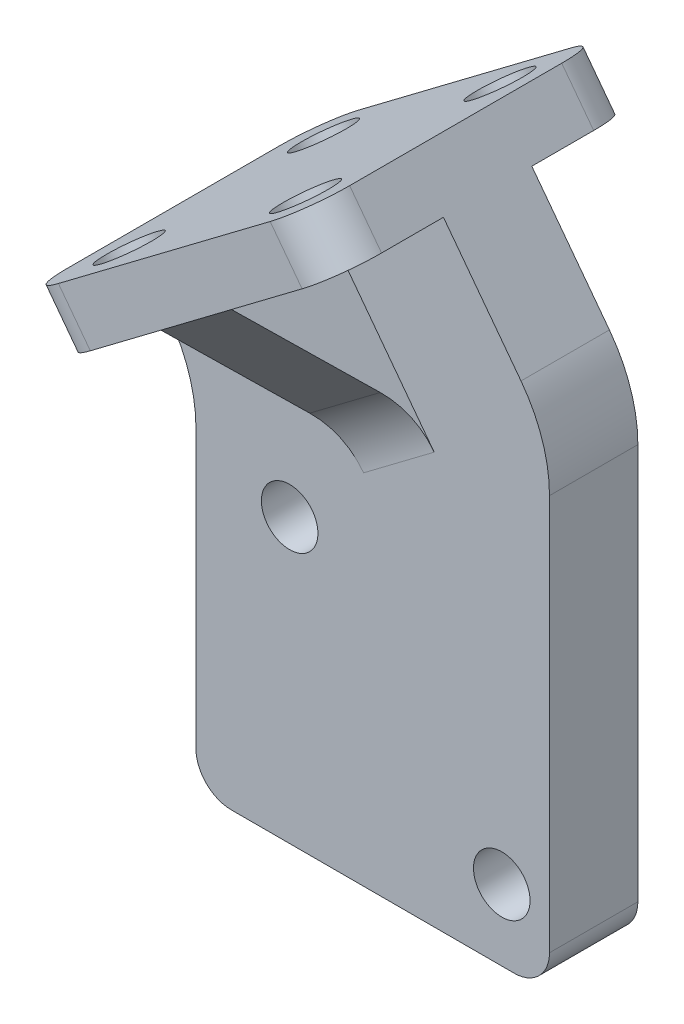
from build123d import *

# Parameters (mm, degrees)
SKETCH_1_R      = 1.6
EXTRUDE_1_DEPTH = 5
SKETCH_2_R      = 1.6
EXTRUDE_2_DEPTH = 3
EXTRUDE_START   = -7.5
EXTRUDE_4_DEPTH = 5
FILLET_1_R      = 5


with BuildPart() as part:
    # 草图1 → 凸台-拉伸1 (new body)
    with BuildSketch(Plane.XY):
        with BuildLine():
            Line((0, 2), (0, 17.705362587))
            ThreePointArc((0, 17.705362587), (-0.413410758, 20.243799839), (-1.61091592, 22.519882772))
            Line((-1.61091592, 22.519882772), (-1.972710201, 23))
            Line((-1.972710201, 23), (14, 35.036300463))
            Line((14, 35.036300463), (18.38908408, 29.211789163))
            ThreePointArc((18.38908408, 29.211789163), (19.586589242, 26.935706229), (20, 24.397268977))
            Line((20, 24.397268977), (20, 2))
            ThreePointArc((20, 2), (19.414213562, 0.585786438), (18, 0))
            Line((18, 0), (2, 0))
            ThreePointArc((2, 0), (0.585786438, 0.585786438), (0, 2))
        make_face()
        with Locations((5.3, 16)):
            Circle(SKETCH_1_R, mode=Mode.SUBTRACT)
        with Locations((17.3, 4)):
            Circle(SKETCH_1_R, mode=Mode.SUBTRACT)
    extrude(amount=EXTRUDE_1_DEPTH)

    # 草图2 → 凸台-拉伸2 (add)
    with BuildSketch(Plane(origin=(-11.768988292, 15.617974969, 0), x_dir=(0.79863551, 0.601815023, 0), z_dir=(-0.601815023, 0.79863551, 0))):
        with BuildLine():
            Line((29.766269115, -11), (14.766269115, -11))
            ThreePointArc((14.766269115, -11), (12.998502162, -10.267766953), (12.266269115, -8.5))
            Line((12.266269115, -8.5), (12.266269115, 3.5))
            ThreePointArc((12.266269115, 3.5), (12.998502162, 5.267766953), (14.766269115, 6))
            Line((14.766269115, 6), (29.766269115, 6))
            ThreePointArc((29.766269115, 6), (31.534036068, 5.267766953), (32.266269115, 3.5))
            Line((32.266269115, 3.5), (32.266269115, -8.5))
            ThreePointArc((32.266269115, -8.5), (31.534036068, -10.267766953), (29.766269115, -11))
        make_face()
        with Locations((16.016269115, 3)):
            Circle(SKETCH_2_R, mode=Mode.SUBTRACT)
        with Locations((28.516269115, 3)):
            Circle(SKETCH_2_R, mode=Mode.SUBTRACT)
        with Locations((28.516269115, -8)):
            Circle(SKETCH_2_R, mode=Mode.SUBTRACT)
        with Locations((16.016269115, -8)):
            Circle(SKETCH_2_R, mode=Mode.SUBTRACT)
    extrude(amount=EXTRUDE_2_DEPTH)

    # 草图6 → 凸台-拉伸4 (add)
    with BuildSketch(Plane(origin=(25.768988292, 19.418325494, 0), x_dir=(0, 0, -1), z_dir=(0.79863551, 0.601815023, 0)).offset(EXTRUDE_START)):
        Polygon((-11, 19.555823366), (-5, 12.262745076), (-5, 19.555823366), align=None)
        Polygon((0, 12.262745076), (6, 19.555823366), (0, 19.555823366), align=None)
    extrude(amount=-EXTRUDE_4_DEPTH)

    # 圆角1
    fillet_1_edges = [part.edges().sort_by_distance(p)[0] for p in [
        (10.40272898, 23.193638931, 5),
        (10.40272898, 23.193638931, 0),
    ]]
    fillet(fillet_1_edges, radius=FILLET_1_R)


solid = part.part
